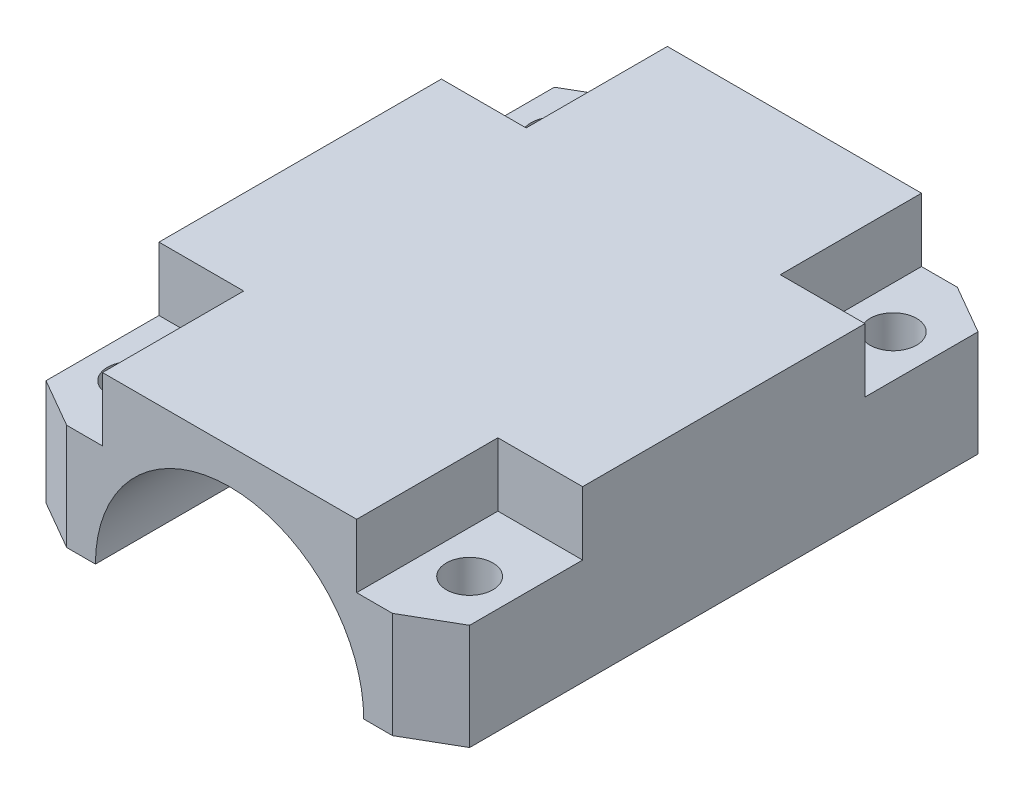
from build123d import *

# Parameters (mm, degrees)
ESBO_O1_W                = 30
ESBO_O1_H                = 40
RESSALTO_EXTRUS_O1_DEPTH = 12
ESBO_O16_W               = 9.5
ESBO_O16_H               = 40
ESBO_O17_R               = 1.65
CORTE_EXTRUS_O12_DEPTH   = 13
CHANFRO1_SIZE            = 2
CHANFRO1_SIZE2           = 3.464101615
CHANFRO1_PART_2_SIZE     = 2
CHANFRO1_PART_2_SIZE2    = 3.464101615
CORTE_EXTRUS_O13_DEPTH   = 4.5


with BuildPart() as part:
    # Esboço1 → Ressalto-extrusão1 (new body)
    with BuildSketch(Plane(origin=(0, 0, 0), x_dir=(1, 0, 0), z_dir=(0, 1, 0))):
        with Locations((-15, 20)):
            Rectangle(ESBO_O1_W, ESBO_O1_H)
    extrude(amount=RESSALTO_EXTRUS_O1_DEPTH)

    # Esboço16 → Corte-Revolução1 (revolve, cut)
    with BuildSketch(Plane.XZ):
        with Locations((-19.75, -20)):
            Rectangle(ESBO_O16_W, ESBO_O16_H)
    revolve(axis=Axis((-15, 0, -40), (0, 0, 1)), mode=Mode.SUBTRACT)

    # Esboço17 → Corte-extrusão12 (cut, through all)
    with BuildSketch(Plane.XZ):
        with Locations((-27, -35)):
            Circle(ESBO_O17_R)
        with Locations((-27, -5)):
            Circle(ESBO_O17_R)
        with Locations((-3, -35)):
            Circle(ESBO_O17_R)
        with Locations((-3, -5)):
            Circle(ESBO_O17_R)
    extrude(amount=-CORTE_EXTRUS_O12_DEPTH, mode=Mode.SUBTRACT)

    # Chanfro1
    chanfro1_edges = [part.edges().sort_by_distance(p)[0] for p in [
        (0, 6, 0),
        (0, 6, -40),
    ]]
    chanfro1_side = [part.faces().sort_by_distance(p)[0] for p in [
        (0, 6, -20),
    ]]
    chamfer(chanfro1_edges, length=CHANFRO1_SIZE, length2=CHANFRO1_SIZE2, reference=chanfro1_side[0])

    # Chanfro1 part 2
    chanfro1_part_2_edges = [part.edges().sort_by_distance(p)[0] for p in [
        (-30, 6, 0),
        (-30, 6, -40),
    ]]
    chanfro1_part_2_side = [part.faces().sort_by_distance(p)[0] for p in [
        (-30, 6, -20),
    ]]
    chamfer(chanfro1_part_2_edges, length=CHANFRO1_PART_2_SIZE, length2=CHANFRO1_PART_2_SIZE2, reference=chanfro1_part_2_side[0])

    # Esboço18 → Corte-extrusão13 (cut)
    with BuildSketch(Plane(origin=(0, 12, 0), x_dir=(1, 0, 0), z_dir=(0, 1, 0))):
        Polygon((-6, 40), (-6, 30), (0, 30), (0, 38), (-3.464101615, 40), align=None)
        Polygon((-24, 40), (-26.535898385, 40), (-30, 38), (-30, 30), (-24, 30), align=None)
        Polygon((0, 10), (0, 2), (-3.464101615, 0), (-6, 0), (-6, 10), align=None)
        Polygon((-24, 0), (-24, 10), (-30, 10), (-30, 2), (-26.535898385, 0), align=None)
    extrude(amount=-CORTE_EXTRUS_O13_DEPTH, mode=Mode.SUBTRACT)


solid = part.part
